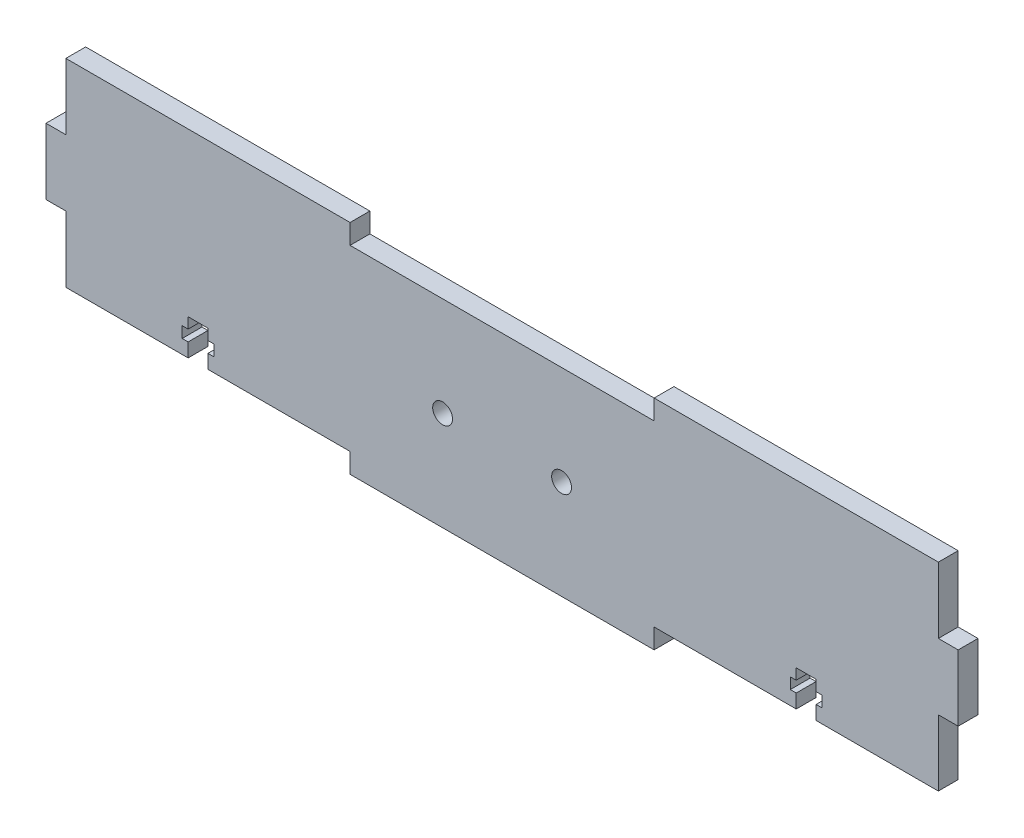
from build123d import *

# Parameters (mm, degrees)
SALIENTE_EXTRUIR1_DEPTH = 5
CORTAR_EXTRUIR1_DEPTH   = 5
CROQUIS3_W              = 76.666666666
CROQUIS3_H              = 5
CORTAR_EXTRUIR2_DEPTH   = 10
CROQUIS4_R              = 2.5
CORTAR_EXTRUIR3_DEPTH   = 10


with BuildPart() as part:
    # Croquis1 → Saliente-Extruir1 (new body)
    with BuildSketch(Plane.XY):
        Polygon((76.666666667, 5), (76.666666667, 0), (153.333333333, 0), (153.333333333, 5), (225, 5), (225, 21.666666667), (230, 21.666666667), (230, 38.333333333), (225, 38.333333333), (225, 55), (5, 55), (5, 38.333333333), (0, 38.333333333), (0, 21.666666667), (5, 21.666666667), (5, 5), align=None)
    extrude(amount=SALIENTE_EXTRUIR1_DEPTH)

    # Croquis2 → Cortar-Extruir1 (cut)
    with BuildSketch(Plane.XY.offset(5)):
        Polygon((35.833333333, 5), (35.833333333, 8.5), (34.333333333, 8.5), (34.333333333, 11.3), (35.833333333, 11.3), (35.833333333, 14), (40.833333333, 14), (40.833333333, 11.3), (42.333333333, 11.3), (42.333333333, 8.5), (40.833333333, 8.5), (40.833333333, 5), align=None)
        Polygon((189.166666667, 5), (189.166666667, 8.5), (187.666666667, 8.5), (187.666666667, 11.3), (189.166666667, 11.3), (189.166666667, 14), (194.166666667, 14), (194.166666667, 11.3), (195.666666667, 11.3), (195.666666667, 8.5), (194.166666667, 8.5), (194.166666667, 5), align=None)
    extrude(amount=-CORTAR_EXTRUIR1_DEPTH, mode=Mode.SUBTRACT)

    # Croquis3 → Cortar-Extruir2 (cut)
    with BuildSketch(Plane.XY.offset(5)):
        with Locations((115, 52.5)):
            Rectangle(CROQUIS3_W, CROQUIS3_H)
    extrude(amount=-CORTAR_EXTRUIR2_DEPTH, mode=Mode.SUBTRACT)

    # Croquis4 → Cortar-Extruir3 (cut)
    with BuildSketch(Plane.XY.offset(5)):
        with Locations((100, 25)):
            Circle(CROQUIS4_R)
        with Locations((130, 25)):
            Circle(CROQUIS4_R)
    extrude(amount=-CORTAR_EXTRUIR3_DEPTH, mode=Mode.SUBTRACT)


solid = part.part
